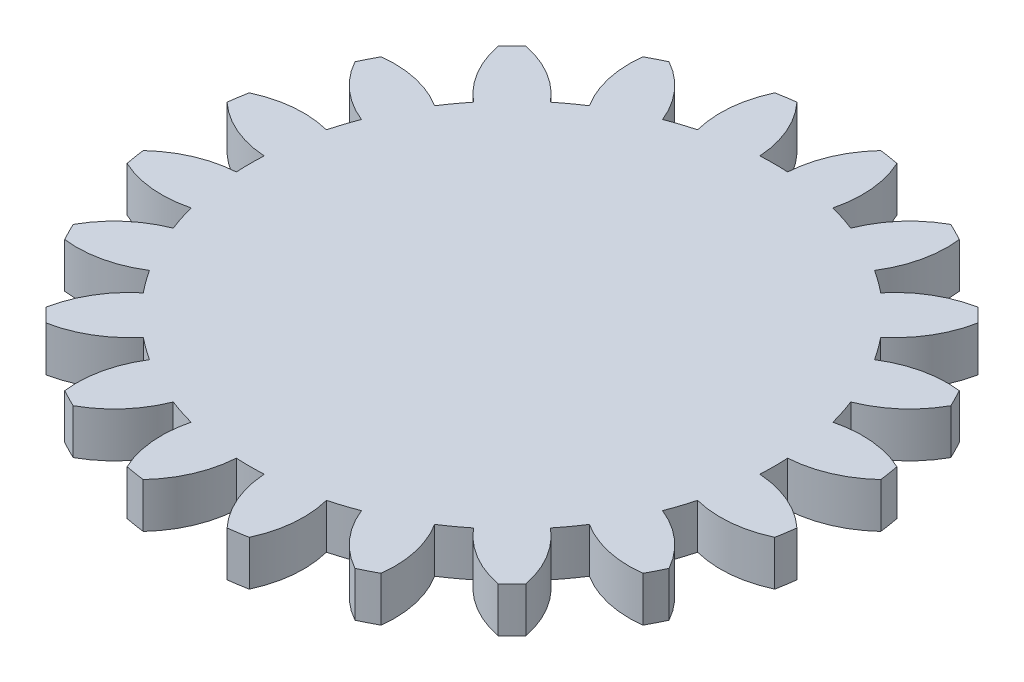
from build123d import *

# Parameters (mm, degrees)
CROQUIS1_R              = 22
SALIENTE_EXTRUIR1_DEPTH = 3
CORTAR_EXTRUIR1_DEPTH   = 3
MATRIZC1_COUNT          = 20


with BuildPart() as part:
    # Croquis1 → Saliente-Extruir1 (new body)
    with BuildSketch(Plane(origin=(0, 0, 0), x_dir=(1, 0, 0), z_dir=(0, 1, 0))):
        with Locations(Location((0, 0, 0), (0, 0, 270))):  # turned: the seam where the file's is
            Circle(CROQUIS1_R)
    extrude(amount=SALIENTE_EXTRUIR1_DEPTH)

    # Croquis2 → Cortar-Extruir1 (cut)
    with BuildSketch(Plane(origin=(0, 3, 0), x_dir=(1, 0, 0), z_dir=(0, 1, 0))):
        with BuildLine():
            ThreePointArc((0.928527245, 17.475349414), (1.485995248, 19.810616222), (2.797926902, 21.821356627))
            ThreePointArc((2.797926902, 21.821356627), (0, 22), (-2.797926902, 21.821356627))
            ThreePointArc((-2.797926902, 21.821356627), (-1.485995248, 19.810616222), (-0.928527245, 17.475349414))
            ThreePointArc((-0.928527245, 17.475349414), (0, 17.5), (0.928527245, 17.475349414))
        make_face()
    cortar_extruir1 = extrude(amount=-CORTAR_EXTRUIR1_DEPTH, mode=Mode.SUBTRACT)

    # MatrizC1: Cortar-Extruir1 ×20 about axis
    matrizc1_axis = Axis((0, 0, 0), (0, 1, 0))
    for i in range(1, MATRIZC1_COUNT):
        add(cortar_extruir1.rotate(matrizc1_axis, i * 360 / MATRIZC1_COUNT), mode=Mode.SUBTRACT)


solid = part.part
